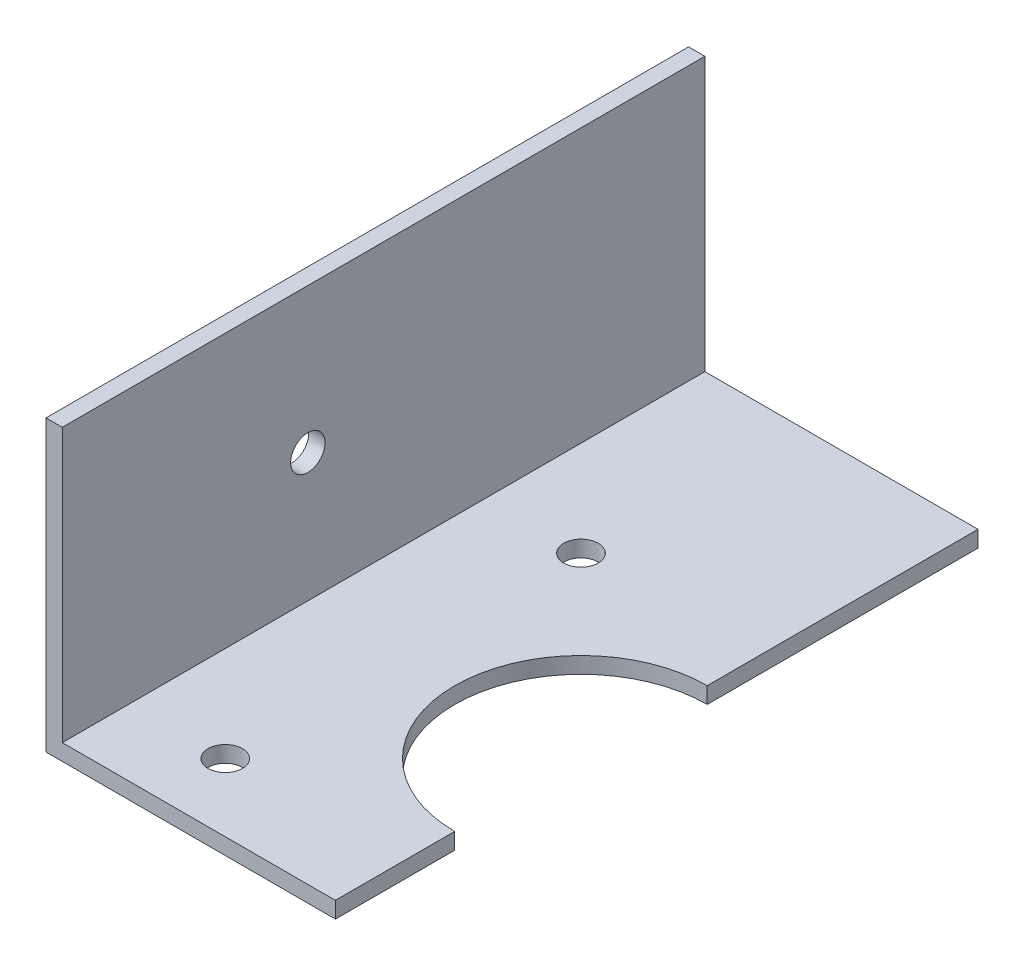
from build123d import *

# Parameters (mm, degrees)
EXTRUDE1_DEPTH     = 56
SKETCH2_R          = 1.5
CUT_EXTRUDE1_DEPTH = 26.22
SKETCH3_R          = 11
CUT_EXTRUDE2_DEPTH = 26.22
SKETCH4_R          = 1.5
CUT_EXTRUDE3_DEPTH = 26.22
SKETCH5_R          = 1.5
CUT_EXTRUDE4_DEPTH = 26.22


with BuildPart() as part:
    # Sketch1 → Extrude1 (new body)
    with BuildSketch(Plane.XY):
        Polygon((0, 0), (0, -25.22), (25.22, -25.22), (25.22, -23.8), (1.42, -23.8), (1.42, 0), align=None)
    extrude(amount=EXTRUDE1_DEPTH)

    # Sketch2 → Cut-Extrude1 (cut, through all)
    with BuildSketch(Plane.ZY):
        with Locations((34.6, -12.61)):
            Circle(SKETCH2_R)
    extrude(amount=-CUT_EXTRUDE1_DEPTH, mode=Mode.SUBTRACT)

    # Sketch3 → Cut-Extrude2 (cut, through all)
    with BuildSketch(Plane.XZ.offset(25.22)):
        with Locations((25.22, 34.6)):
            Circle(SKETCH3_R)
    extrude(amount=-CUT_EXTRUDE2_DEPTH, mode=Mode.SUBTRACT)

    # Sketch4 → Cut-Extrude3 (cut, through all)
    with BuildSketch(Plane.XZ.offset(25.22)):
        with Locations((9.72, 19.1)):
            Circle(SKETCH4_R)
    extrude(amount=-CUT_EXTRUDE3_DEPTH, mode=Mode.SUBTRACT)

    # Sketch5 → Cut-Extrude4 (cut, through all)
    with BuildSketch(Plane.XZ.offset(25.22)):
        with Locations((9.72, 50.1)):
            Circle(SKETCH5_R)
    extrude(amount=-CUT_EXTRUDE4_DEPTH, mode=Mode.SUBTRACT)


solid = part.part
